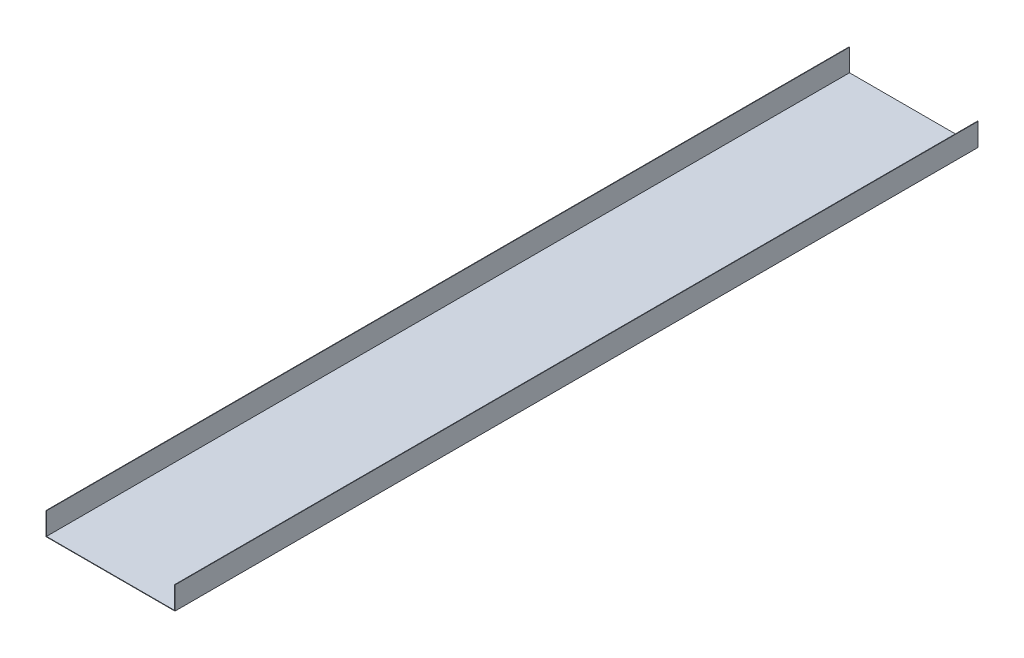
from build123d import *

# Parameters (mm, degrees)
SKETCH_1_W      = 13550
SKETCH_1_H      = 85000
EXTRUDE_1_DEPTH = 50
SKETCH_2_W      = 50
SKETCH_2_H      = 2400
EXTRUDE_2_DEPTH = 85000


with BuildPart() as part:
    # 草圖1 → 填料-伸長1 (new body)
    with BuildSketch(Plane(origin=(0, 0, 0), x_dir=(1, 0, 0), z_dir=(0, 1, 0))):
        Rectangle(SKETCH_1_W, SKETCH_1_H)
    extrude(amount=-EXTRUDE_1_DEPTH)

    # 草圖2 → 填料-伸長2 (add)
    with BuildSketch(Plane.XY.offset(42500)):
        with Locations((-6800, 1150)):
            Rectangle(SKETCH_2_W, SKETCH_2_H)
        with Locations((6800, 1150)):
            Rectangle(SKETCH_2_W, SKETCH_2_H)
    extrude(amount=-EXTRUDE_2_DEPTH)


solid = part.part
